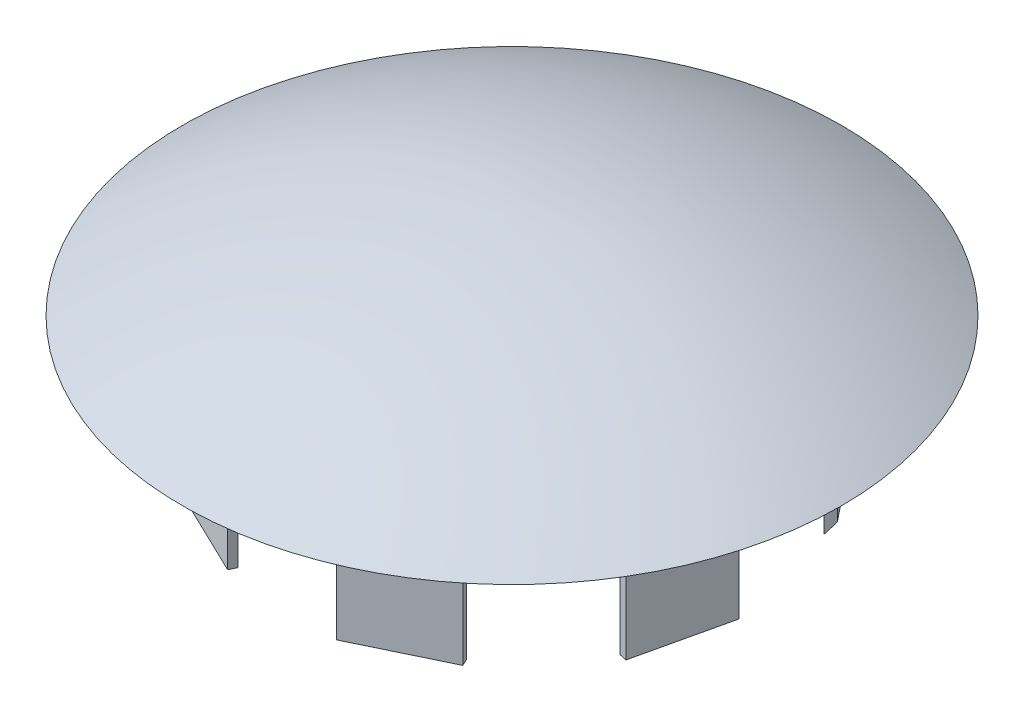
from build123d import *

# Parameters (mm, degrees)
SKETCH1_W                       = 24.199471414
SKETCH1_H                       = 2
BOSS_EXTRUDE1_DEPTH             = 35
BOSS_EXTRUDE1_DIRECTION_2_REACH = 26.277


with BuildPart() as part:
    # Sketch6 → Revolve3 (revolve)
    with BuildSketch(Plane.XY.offset(-46.235660898)):
        with BuildLine():
            Line((16.206828031, 19.733449427), (16.206828031, 24.27673627))
            add(Edge.make_bspline(
                [(100.543718281, 0), (66.637702737, 19.683925925), (36.295673337, 23.877083975), (16.206828031, 24.27673627)],
                knots=[0, 0, 0, 0, 1, 1, 1, 1], degree=3))
            add(Edge.make_bspline(
                [(16.206828031, 19.733449427), (44.550281864, 20.046720972), (71.658331759, 8.477286849), (100.543718281, 0)],
                knots=[0, 0, 0, 0, 1, 1, 1, 1], degree=3))
        make_face()
    revolve(axis=Axis((16.206828031, 19.733449427, -46.235660898), (0, 1, 0)))

    # Sketch1 → Boss-Extrude1 (add)
    with BuildSketch(Plane(origin=(0, 0, 0), x_dir=(1, 0, 0), z_dir=(0, 1, 0))):
        with Locations((19.440545507, 104.374561644)):
            Rectangle(SKETCH1_W, SKETCH1_H)
        Polygon((68.633841253, 77.067834217), (57.432693736, 91.113628939), (55.869030771, 89.866649335), (69.659558116, 72.573875009), align=None)
        Polygon((72.129937387, 19.465930814), (77.514826367, 43.058670955), (75.564970543, 43.503712823), (70.180081563, 19.910972681), align=None)
        Polygon((30.661981859, -13.103705945), (52.464952222, -2.603948803), (51.597184744, -0.802011068), (29.79421438, -11.301768209), align=None)
        Polygon((-20.656832908, -0.989589169), (1.146137456, -11.48934631), (2.013904934, -9.687408574), (-19.78906543, 0.812348567), align=None)
        Polygon((-43.18239268, 46.686104127), (-37.7975037, 23.093363986), (-35.847647875, 23.538405854), (-41.232536856, 47.131145995), align=None)
        Polygon((-19.952491512, 94.022604484), (-35.040615149, 75.102695874), (-33.476952184, 73.85571627), (-18.388828547, 92.77562488), align=None)
    extrude(amount=-BOSS_EXTRUDE1_DEPTH)

    # Sketch1 → Boss-Extrude1 direction 2 (add, up to next)
    with BuildSketch(Plane(origin=(0, 0, 0), x_dir=(1, 0, 0), z_dir=(0, 1, 0)), mode=Mode.PRIVATE) as boss_extrude1_direction_2_sk1:
        with Locations((19.440545507, 104.374561644)):
            Rectangle(SKETCH1_W, SKETCH1_H)
    boss_extrude1_direction_2_tool1 = extrude(boss_extrude1_direction_2_sk1.sketch, amount=BOSS_EXTRUDE1_DIRECTION_2_REACH, mode=Mode.PRIVATE) - part.part
    add(boss_extrude1_direction_2_tool1.solids().sort_by_distance((19.440546, 0, -104.374562))[0])
    # Sketch1 → Boss-Extrude1 direction 2 (add, up to next)
    with BuildSketch(Plane(origin=(0, 0, 0), x_dir=(1, 0, 0), z_dir=(0, 1, 0)), mode=Mode.PRIVATE) as boss_extrude1_direction_2_sk2:
        Polygon((68.633841253, 77.067834217), (57.432693736, 91.113628939), (55.869030771, 89.866649335), (69.659558116, 72.573875009), align=None)
    boss_extrude1_direction_2_tool2 = extrude(boss_extrude1_direction_2_sk2.sketch, amount=BOSS_EXTRUDE1_DIRECTION_2_REACH, mode=Mode.PRIVATE) - part.part
    add(boss_extrude1_direction_2_tool2.solids().sort_by_distance((62.894136, 0, -82.605929))[0])
    # Sketch1 → Boss-Extrude1 direction 2 (add, up to next)
    with BuildSketch(Plane(origin=(0, 0, 0), x_dir=(1, 0, 0), z_dir=(0, 1, 0)), mode=Mode.PRIVATE) as boss_extrude1_direction_2_sk3:
        Polygon((72.129937387, 19.465930814), (77.514826367, 43.058670955), (75.564970543, 43.503712823), (70.180081563, 19.910972681), align=None)
    boss_extrude1_direction_2_tool3 = extrude(boss_extrude1_direction_2_sk3.sketch, amount=BOSS_EXTRUDE1_DIRECTION_2_REACH, mode=Mode.PRIVATE) - part.part
    add(boss_extrude1_direction_2_tool3.solids().sort_by_distance((73.847454, 0, -31.484822))[0])
    # Sketch1 → Boss-Extrude1 direction 2 (add, up to next)
    with BuildSketch(Plane(origin=(0, 0, 0), x_dir=(1, 0, 0), z_dir=(0, 1, 0)), mode=Mode.PRIVATE) as boss_extrude1_direction_2_sk4:
        Polygon((30.661981859, -13.103705945), (52.464952222, -2.603948803), (51.597184744, -0.802011068), (29.79421438, -11.301768209), align=None)
    boss_extrude1_direction_2_tool4 = extrude(boss_extrude1_direction_2_sk4.sketch, amount=BOSS_EXTRUDE1_DIRECTION_2_REACH, mode=Mode.PRIVATE) - part.part
    add(boss_extrude1_direction_2_tool4.solids().sort_by_distance((41.129583, 0, 6.952859))[0])
    # Sketch1 → Boss-Extrude1 direction 2 (add, up to next)
    with BuildSketch(Plane(origin=(0, 0, 0), x_dir=(1, 0, 0), z_dir=(0, 1, 0)), mode=Mode.PRIVATE) as boss_extrude1_direction_2_sk5:
        Polygon((-20.656832908, -0.989589169), (1.146137456, -11.48934631), (2.013904934, -9.687408574), (-19.78906543, 0.812348567), align=None)
    boss_extrude1_direction_2_tool5 = extrude(boss_extrude1_direction_2_sk5.sketch, amount=BOSS_EXTRUDE1_DIRECTION_2_REACH, mode=Mode.PRIVATE) - part.part
    add(boss_extrude1_direction_2_tool5.solids().sort_by_distance((-9.321464, 0, 5.338499))[0])
    # Sketch1 → Boss-Extrude1 direction 2 (add, up to next)
    with BuildSketch(Plane(origin=(0, 0, 0), x_dir=(1, 0, 0), z_dir=(0, 1, 0)), mode=Mode.PRIVATE) as boss_extrude1_direction_2_sk6:
        Polygon((-43.18239268, 46.686104127), (-37.7975037, 23.093363986), (-35.847647875, 23.538405854), (-41.232536856, 47.131145995), align=None)
    boss_extrude1_direction_2_tool6 = extrude(boss_extrude1_direction_2_sk6.sketch, amount=BOSS_EXTRUDE1_DIRECTION_2_REACH, mode=Mode.PRIVATE) - part.part
    add(boss_extrude1_direction_2_tool6.solids().sort_by_distance((-39.51502, 0, -35.112255))[0])
    # Sketch1 → Boss-Extrude1 direction 2 (add, up to next)
    with BuildSketch(Plane(origin=(0, 0, 0), x_dir=(1, 0, 0), z_dir=(0, 1, 0)), mode=Mode.PRIVATE) as boss_extrude1_direction_2_sk7:
        Polygon((-19.952491512, 94.022604484), (-35.040615149, 75.102695874), (-33.476952184, 73.85571627), (-18.388828547, 92.77562488), align=None)
    boss_extrude1_direction_2_tool7 = extrude(boss_extrude1_direction_2_sk7.sketch, amount=BOSS_EXTRUDE1_DIRECTION_2_REACH, mode=Mode.PRIVATE) - part.part
    add(boss_extrude1_direction_2_tool7.solids().sort_by_distance((-26.714722, 0, -83.93916))[0])


solid = part.part
